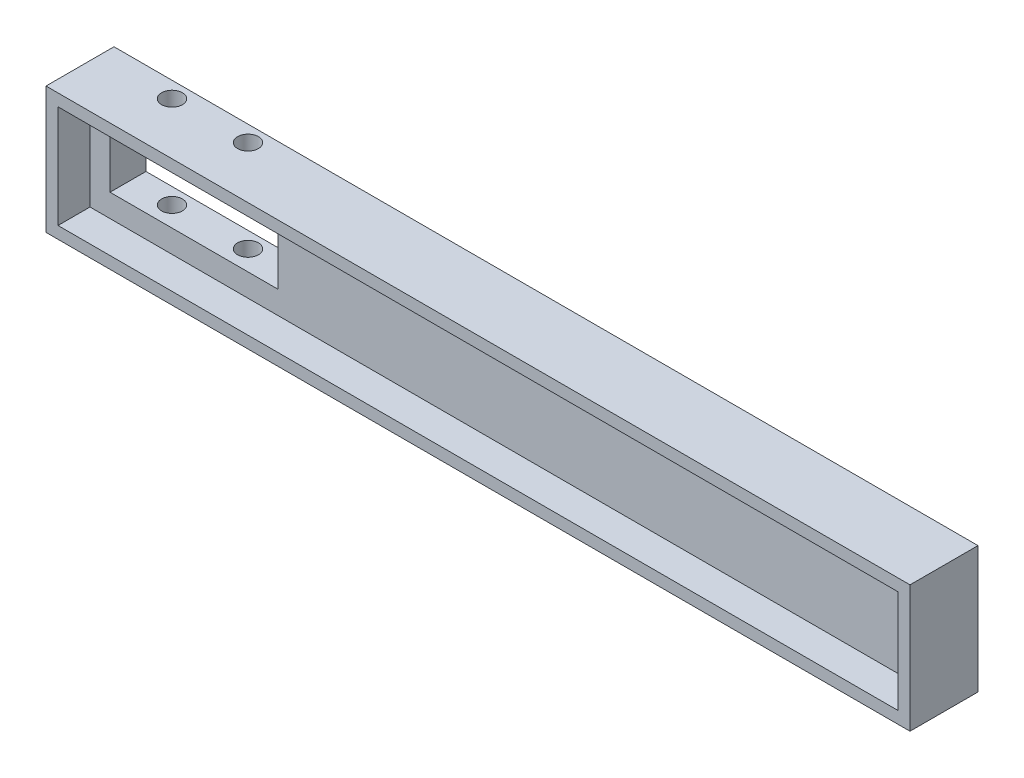
from build123d import *

# Parameters (mm, degrees)
RESSALTO_EXTRUS_O1_DEPTH      = 5
RESSALTO_EXTRUS_O1_DEPTH_BACK = 3.5
ESBO_O1_3_W                   = 105
ESBO_O1_3_H                   = 12.85
ESBO_O1_3_W_2                 = 21
ESBO_O1_3_H_2                 = 7.5
RESSALTO_EXTRUS_O2_DEPTH      = 3.5
ESBO_O1_4_W                   = 105
ESBO_O1_4_H                   = 12.85
ESBO_O1_4_W_2                 = 21
ESBO_O1_4_H_2                 = 7.5
RESSALTO_EXTRUS_O3_DEPTH      = 1
ESBO_O2_R                     = 1.3
CORTE_EXTRUS_O2_DEPTH         = 110.701267602


with BuildPart() as part:
    # Esboço1 → Ressalto-extrusão1 (new, two sides: drawn at the far end of the back side and taken through both)
    with BuildSketch(Plane.XY.offset(-RESSALTO_EXTRUS_O1_DEPTH_BACK)):
        Polygon((-106, 18.391143911), (-106, 2.541143911), (-93, 2.541143911), (2, 2.541143911), (2, 18.391143911), (-95, 18.391143911), align=None)
        Polygon((-96.5, 16.891143911), (0.5, 16.891143911), (0.5, 4.041143911), (-94.5, 4.041143911), (-104.5, 4.041143911), (-104.5, 16.891143911), align=None, mode=Mode.SUBTRACT)
    extrude(amount=RESSALTO_EXTRUS_O1_DEPTH + RESSALTO_EXTRUS_O1_DEPTH_BACK)

    # Esboço1<3> → Ressalto-extrusão2 (add)
    with BuildSketch(Plane.XY):
        with Locations((-52, 10.466143911)):
            Rectangle(ESBO_O1_3_W, ESBO_O1_3_H)
        with Locations((-91.5, 10.641143911)):
            Rectangle(ESBO_O1_3_W_2, ESBO_O1_3_H_2, mode=Mode.SUBTRACT)
    extrude(amount=-RESSALTO_EXTRUS_O2_DEPTH)

    # Esboço1<4> → Ressalto-extrusão3 (add)
    with BuildSketch(Plane.XY):
        with Locations((-52, 10.466143911)):
            Rectangle(ESBO_O1_4_W, ESBO_O1_4_H)
        with Locations((-91.5, 10.641143911)):
            Rectangle(ESBO_O1_4_W_2, ESBO_O1_4_H_2, mode=Mode.SUBTRACT)
    extrude(amount=RESSALTO_EXTRUS_O3_DEPTH)

    # Esboço2 → Corte-extrusão2 (cut, through all)
    with BuildSketch(Plane(origin=(0, 18.391143911, -18.391143911), x_dir=(1, 0, 0), z_dir=(0, -1, 0))):
        with Locations((-96.75, 16.891143911)):
            Circle(ESBO_O2_R)
        with Locations((-87.25, 16.891143911)):
            Circle(ESBO_O2_R)
    extrude(amount=CORTE_EXTRUS_O2_DEPTH, mode=Mode.SUBTRACT)


solid = part.part
